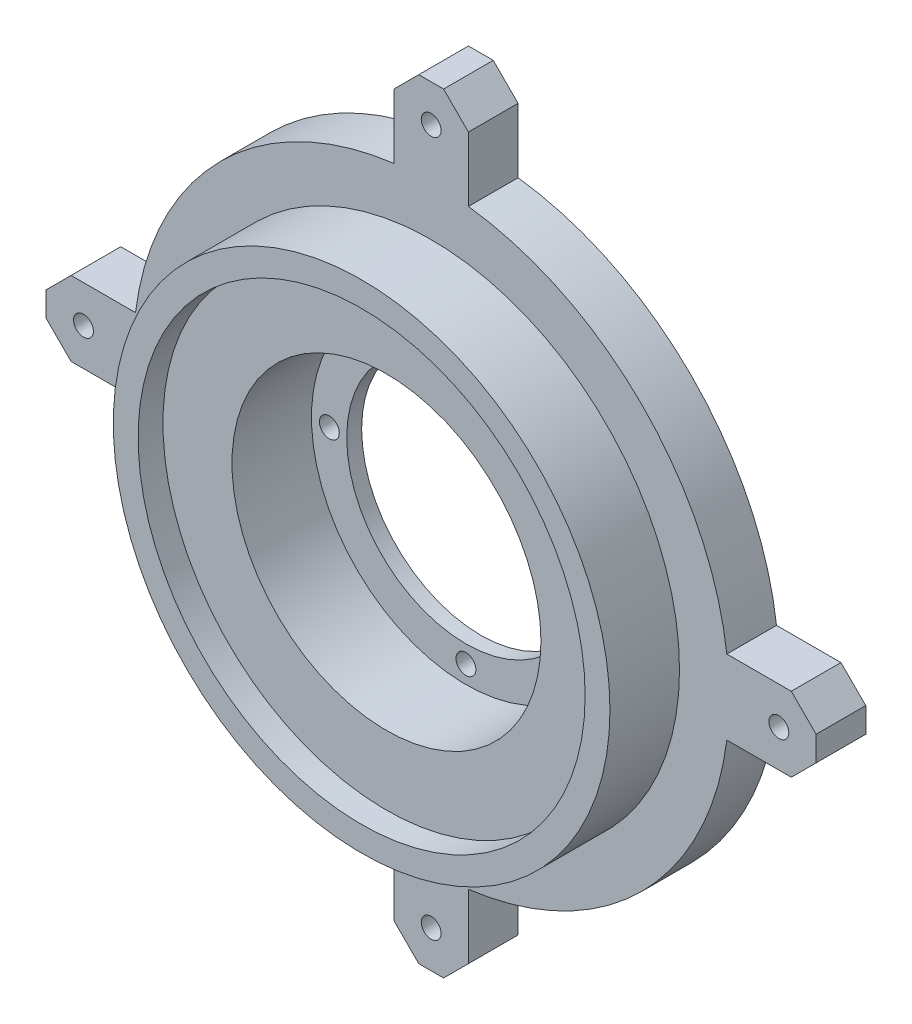
from build123d import *

# Parameters (mm, degrees)
BOSS_EXTRUDE1_DEPTH             = 10
SKETCH2_R                       = 50
BOSS_EXTRUDE2_DEPTH             = 14
SKETCH3_R                       = 31.1
CUT_EXTRUDE1_DEPTH              = 21
F_4_0MM_DOWEL_HOLE1_D           = 4
F_4_0MM_DOWEL_HOLE1_CSINK_D     = 4.05
F_4_0MM_DOWEL_HOLE1_CSINK_ANGLE = 90
SKETCH11_R                      = 45
CUT_EXTRUDE2_DEPTH              = 5
SKETCH4_R                       = 24
CUT_EXTRUDE3_DEPTH              = 4
SKETCH12_R                      = 2
CUT_EXTRUDE5_DEPTH              = 4


with BuildPart() as part:
    # Sketch1 → Boss-Extrude1 (new body)
    with BuildSketch(Plane.XY):
        with BuildLine():
            Line((-42.5, 7.5), (-59.529404499, 7.5))
            ThreePointArc((-59.529404499, 7.5), (-60, 0), (-59.529404499, -7.5))
            Line((-59.529404499, -7.5), (-42.5, -7.5))
            Line((-42.5, -7.5), (-42.5, 7.5))
        make_face()
        with BuildLine():
            ThreePointArc((-7.5, 59.529404499), (-42.426406871, 42.426406871), (-59.529404499, 7.5))
            Line((-59.529404499, 7.5), (-42.5, 7.5))
            Line((-42.5, 7.5), (-42.5, -7.5))
            Line((-42.5, -7.5), (-59.529404499, -7.5))
            ThreePointArc((-59.529404499, -7.5), (-42.426406871, -42.426406871), (-7.5, -59.529404499))
            Line((-7.5, -59.529404499), (-7.5, -42.5))
            Line((-7.5, -42.5), (7.5, -42.5))
            Line((7.5, -42.5), (7.5, -59.529404499))
            ThreePointArc((7.5, -59.529404499), (42.426406871, -42.426406871), (59.529404499, -7.5))
            Line((59.529404499, -7.5), (42.5, -7.5))
            Line((42.5, -7.5), (42.5, 7.5))
            Line((42.5, 7.5), (59.529404499, 7.5))
            ThreePointArc((59.529404499, 7.5), (42.426406871, 42.426406871), (7.5, 59.529404499))
            Line((7.5, 59.529404499), (7.5, 42.5))
            Line((7.5, 42.5), (-7.5, 42.5))
            Line((-7.5, 42.5), (-7.5, 59.529404499))
        make_face()
        with BuildLine():
            ThreePointArc((7.5, 59.529404499), (0, 60), (-7.5, 59.529404499))
            Line((-7.5, 59.529404499), (-7.5, 42.5))
            Line((-7.5, 42.5), (7.5, 42.5))
            Line((7.5, 42.5), (7.5, 59.529404499))
        make_face()
        with BuildLine():
            Line((-7.5, 72.5), (-7.5, 59.529404499))
            ThreePointArc((-7.5, 59.529404499), (0, 60), (7.5, 59.529404499))
            Line((7.5, 59.529404499), (7.5, 72.5))
            Line((7.5, 72.5), (2.5, 77.5))
            Line((2.5, 77.5), (-2.5, 77.5))
            Line((-2.5, 77.5), (-7.5, 72.5))
        make_face()
        with BuildLine():
            Line((-59.529404499, 7.5), (-72.5, 7.5))
            Line((-72.5, 7.5), (-77.5, 2.5))
            Line((-77.5, 2.5), (-77.5, -2.5))
            Line((-77.5, -2.5), (-72.5, -7.5))
            Line((-72.5, -7.5), (-59.529404499, -7.5))
            ThreePointArc((-59.529404499, -7.5), (-60, 0), (-59.529404499, 7.5))
        make_face()
        with BuildLine():
            ThreePointArc((60, 0), (59.882235554, 3.757374753), (59.529404499, 7.5))
            Line((59.529404499, 7.5), (42.5, 7.5))
            Line((42.5, 7.5), (42.5, -7.5))
            Line((42.5, -7.5), (59.529404499, -7.5))
            ThreePointArc((59.529404499, -7.5), (59.882235554, -3.757374753), (60, 0))
        make_face()
        with BuildLine():
            Line((72.5, 7.5), (59.529404499, 7.5))
            ThreePointArc((59.529404499, 7.5), (59.882235554, 3.757374753), (60, 0))
            ThreePointArc((60, 0), (59.882235554, -3.757374753), (59.529404499, -7.5))
            Line((59.529404499, -7.5), (72.5, -7.5))
            Line((72.5, -7.5), (77.5, -2.5))
            Line((77.5, -2.5), (77.5, 2.5))
            Line((77.5, 2.5), (72.5, 7.5))
        make_face()
        with BuildLine():
            ThreePointArc((7.5, -59.529404499), (0, -60), (-7.5, -59.529404499))
            Line((-7.5, -59.529404499), (-7.5, -72.5))
            Line((-7.5, -72.5), (-2.5, -77.5))
            Line((-2.5, -77.5), (2.5, -77.5))
            Line((2.5, -77.5), (7.5, -72.5))
            Line((7.5, -72.5), (7.5, -59.529404499))
        make_face()
        with BuildLine():
            Line((-7.5, -42.5), (-7.5, -59.529404499))
            ThreePointArc((-7.5, -59.529404499), (0, -60), (7.5, -59.529404499))
            Line((7.5, -59.529404499), (7.5, -42.5))
            Line((7.5, -42.5), (-7.5, -42.5))
        make_face()
    extrude(amount=BOSS_EXTRUDE1_DEPTH)

    # Sketch2 → Boss-Extrude2 (add)
    with BuildSketch(Plane.XY.offset(10)):
        Circle(SKETCH2_R)
    extrude(amount=BOSS_EXTRUDE2_DEPTH)

    # Sketch3 → Cut-Extrude1 (cut)
    with BuildSketch(Plane.XY.offset(24)):
        Circle(SKETCH3_R)
    extrude(amount=-CUT_EXTRUDE1_DEPTH, mode=Mode.SUBTRACT)

    # Ø4.0mm Dowel Hole1 (through all)
    with Locations(Plane(origin=(0, 0, 0), x_dir=(-1, 0, 0), z_dir=(0, 0, -1))):
        with Locations((-70, 0), (0, 70), (70, 0), (0, -70)):
            CounterSinkHole(F_4_0MM_DOWEL_HOLE1_D / 2, F_4_0MM_DOWEL_HOLE1_CSINK_D / 2, counter_sink_angle=F_4_0MM_DOWEL_HOLE1_CSINK_ANGLE)

    # Sketch11 → Cut-Extrude2 (cut)
    with BuildSketch(Plane.XY.offset(24)):
        Circle(SKETCH11_R)
    extrude(amount=-CUT_EXTRUDE2_DEPTH, mode=Mode.SUBTRACT)

    # Sketch4 → Cut-Extrude3 (cut)
    with BuildSketch(Plane(origin=(0, 0, 0), x_dir=(-1, 0, 0), z_dir=(0, 0, -1))):
        Circle(SKETCH4_R)
    extrude(amount=-CUT_EXTRUDE3_DEPTH, mode=Mode.SUBTRACT)

    # Sketch12 → Cut-Extrude5 (cut)
    with BuildSketch(Plane(origin=(0, 0, 0), x_dir=(-1, 0, 0), z_dir=(0, 0, -1))):
        with Locations((27.5, 0)):
            Circle(SKETCH12_R)
        with Locations((0, -27.5)):
            Circle(SKETCH12_R)
        with Locations((-27.5, 0)):
            Circle(SKETCH12_R)
        with Locations((0, 27.5)):
            Circle(SKETCH12_R)
    extrude(amount=-CUT_EXTRUDE5_DEPTH, mode=Mode.SUBTRACT)


solid = part.part
